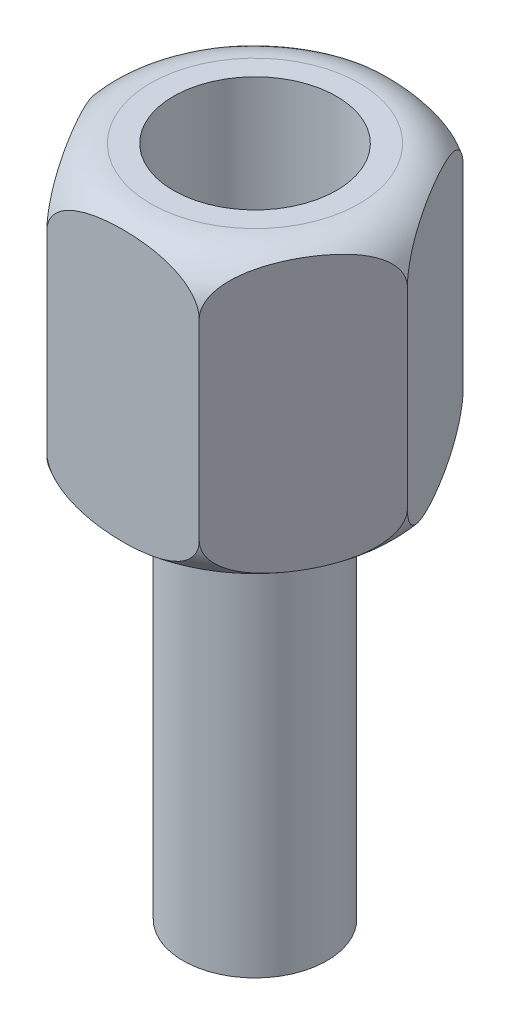
from build123d import *

# Parameters (mm, degrees)
BOSS_EXTRUDE1_DEPTH      = 6
M3_CLEARANCE_HOLE1_D     = 3.4
M3_CLEARANCE_HOLE1_DEPTH = 12
M3_CLEARANCE_HOLE1_TIP   = 1.021463052
SKETCH5_R                = 1.5
BOSS_EXTRUDE2_DEPTH      = 8


with BuildPart() as part:
    # Sketch1 → Boss-Extrude1 (new body)
    with BuildSketch(Plane(origin=(0, 0, 0), x_dir=(1, 0, 0), z_dir=(0, 1, 0))):
        Polygon((3.175426481, 0), (1.58771324, 2.75), (-1.58771324, 2.75), (-3.175426481, 0), (-1.58771324, -2.75), (1.58771324, -2.75), align=None)
    extrude(amount=BOSS_EXTRUDE1_DEPTH)

    # M3 Clearance Hole1
    with Locations(Plane(origin=(0, 6, 0), x_dir=(-1, 0, 0), z_dir=(0, 1, 0))):
        with Locations((0, 0)):
            Hole(M3_CLEARANCE_HOLE1_D / 2, depth=M3_CLEARANCE_HOLE1_DEPTH)
            with Locations((0, 0, -(M3_CLEARANCE_HOLE1_DEPTH + M3_CLEARANCE_HOLE1_TIP / 2))):  # 118° drill point
                Cone(0, M3_CLEARANCE_HOLE1_D / 2, M3_CLEARANCE_HOLE1_TIP, mode=Mode.SUBTRACT)

    # Sketch4 → Cut-Revolve1 (revolve, cut)
    with BuildSketch(Plane.XY):
        with BuildLine():
            Line((-2.175426481, 6), (-3.175426481, 6))
            Line((-3.175426481, 6), (-3.175426481, 5))
            ThreePointArc((-3.175426481, 5), (-2.882533262, 5.707106781), (-2.175426481, 6))
        make_face()
        with BuildLine():
            Line((-3.175426481, 1), (-3.175426481, 0))
            Line((-3.175426481, 0), (-2.175426481, 0))
            ThreePointArc((-2.175426481, 0), (-2.882533262, 0.292893219), (-3.175426481, 1))
        make_face()
    revolve(axis=Axis((0, 6, 0), (0, -1, 0)), mode=Mode.SUBTRACT)


with BuildPart() as body_2:
    # Sketch5 → Boss-Extrude2 (new body)
    with BuildSketch(Plane.XZ):
        Circle(SKETCH5_R)
    extrude(amount=BOSS_EXTRUDE2_DEPTH)


solid = Compound([part.part, body_2.part])
